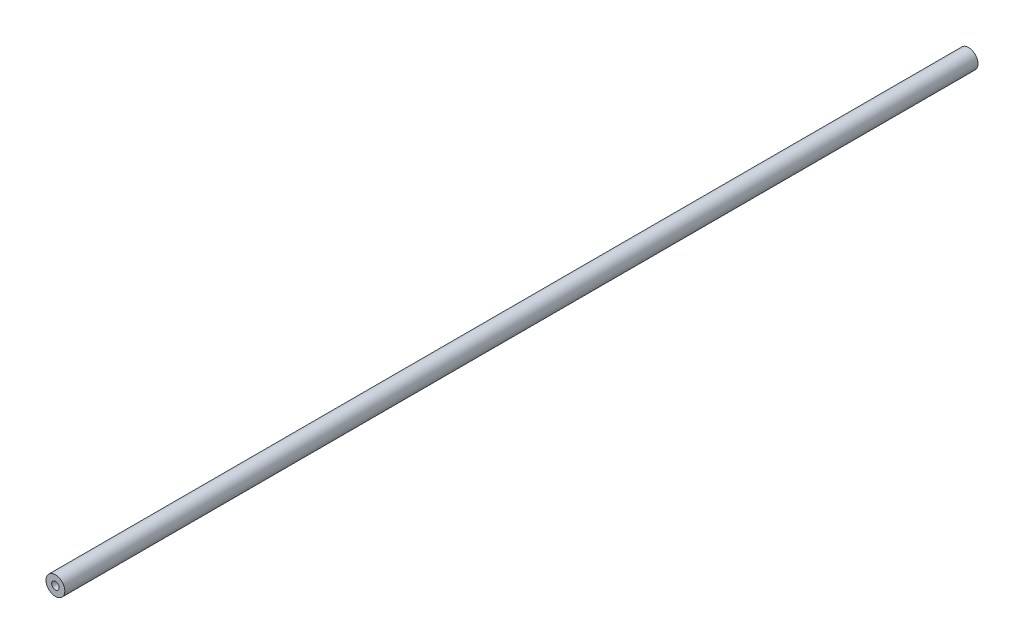
from build123d import *

# Parameters (mm, degrees)
SKETCH1_R          = 3.175
EXTRUDE1_DEPTH     = 307.975
SKETCH2_R          = 1.27
CUT_EXTRUDE1_DEPTH = 308.975


with BuildPart() as part:
    # Sketch1 → Extrude1 (new body)
    with BuildSketch(Plane.XY):
        Circle(SKETCH1_R)
    extrude(amount=EXTRUDE1_DEPTH)

    # Sketch2 → Cut-Extrude1 (cut, through all)
    with BuildSketch(Plane.XY.offset(307.975)):
        Circle(SKETCH2_R)
    extrude(amount=-CUT_EXTRUDE1_DEPTH, mode=Mode.SUBTRACT)


solid = part.part
